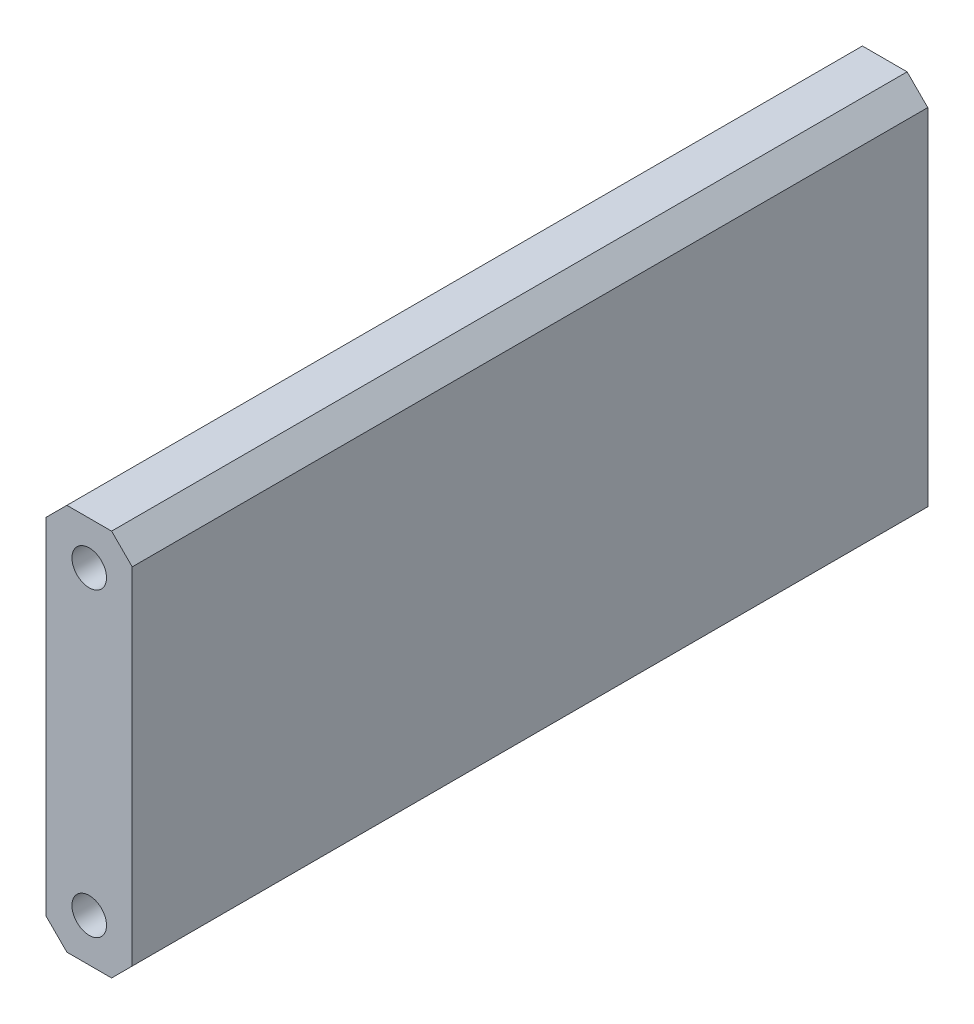
from build123d import *

# Parameters (mm, degrees)
BOSS_EXTRUDE1_DEPTH         = 117.475
F_1_4_20_TAPPED_HOLE1_D     = 5.1054
F_1_4_20_TAPPED_HOLE1_DEPTH = 22.86
F_1_4_20_TAPPED_HOLE1_TIP   = 1.533816902
F_1_4_20_TAPPED_HOLE2_D     = 5.1054
F_1_4_20_TAPPED_HOLE2_DEPTH = 23.9014
F_1_4_20_TAPPED_HOLE2_TIP   = 1.533816902


with BuildPart() as part:
    # Sketch1 → Boss-Extrude1 (new body)
    with BuildSketch(Plane.XY):
        Polygon((-3.302, 6.35), (-6.35, 3.302), (-6.35, -47.752), (-3.302, -50.8), (3.302, -50.8), (6.35, -47.752), (6.35, 3.302), (3.302, 6.35), align=None)
    extrude(amount=BOSS_EXTRUDE1_DEPTH)

    # 1/4-20 Tapped Hole1
    with Locations(Plane.XY.offset(117.475)):
        with Locations((0, 0), (0, -44.45)):
            Hole(F_1_4_20_TAPPED_HOLE1_D / 2, depth=F_1_4_20_TAPPED_HOLE1_DEPTH)
            with Locations((0, 0, -(F_1_4_20_TAPPED_HOLE1_DEPTH + F_1_4_20_TAPPED_HOLE1_TIP / 2))):  # 118° drill point
                Cone(0, F_1_4_20_TAPPED_HOLE1_D / 2, F_1_4_20_TAPPED_HOLE1_TIP, mode=Mode.SUBTRACT)

    # 1/4-20 Tapped Hole2
    with Locations(Plane(origin=(0, 0, 0), x_dir=(-1, 0, 0), z_dir=(0, 0, -1))):
        with Locations((0, 0), (0, -44.243867412)):
            Hole(F_1_4_20_TAPPED_HOLE2_D / 2, depth=F_1_4_20_TAPPED_HOLE2_DEPTH)
            with Locations((0, 0, -(F_1_4_20_TAPPED_HOLE2_DEPTH + F_1_4_20_TAPPED_HOLE2_TIP / 2))):  # 118° drill point
                Cone(0, F_1_4_20_TAPPED_HOLE2_D / 2, F_1_4_20_TAPPED_HOLE2_TIP, mode=Mode.SUBTRACT)


solid = part.part
